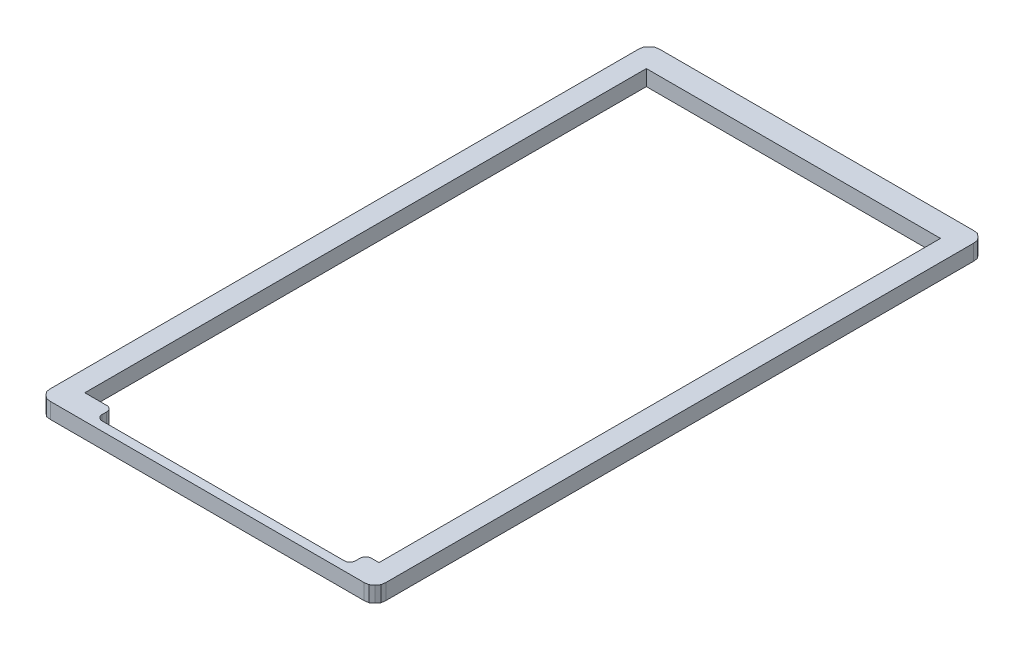
from build123d import *

# Parameters (mm, degrees)
AUFSATZ_LINEAR_AUSTRAGEN1_DEPTH = 1.4


with BuildPart() as part:
    # Skizze1 → Aufsatz-Linear austragen1 (new body)
    with BuildSketch(Plane(origin=(0, 0, 0), x_dir=(1, 0, 0), z_dir=(0, 1, 0))):
        Polygon((14.409630658, 25.21028647), (14.016111454, 25.259411872), (-14.016755293, 25.259390001), (-14.409855506, 25.210248977), (-14.705374814, 24.96453136), (-14.950840446, 24.669672719), (-15.000118678, 24.276547653), (-15.000218735, -28.257278341), (-14.95104056, -28.650375287), (-14.705137178, -28.945646353), (-14.410055621, -29.190951545), (-14.016949154, -29.240173804), (14.015942607, -29.240255039), (14.409480572, -29.191114015), (14.704562129, -28.945396398), (14.950465511, -28.650537758), (14.999712475, -28.257315834), (14.999781265, 24.276613266), (14.95060309, 24.669716461), (14.704274464, 24.964575102), align=None)
        with BuildLine():
            Line((11.462718603, -28.440255039), (-10.193671543, -28.440255039))
            ThreePointArc((-10.193671543, -28.440255039), (-10.547224933, -28.29380843), (-10.693671543, -27.940255039))
            Line((-10.693671543, -27.940255039), (-10.693671543, -27.530609999))
            ThreePointArc((-10.693671543, -27.530609999), (-10.840118152, -27.177056609), (-11.193671543, -27.030609999))
            Line((-11.193671543, -27.030609999), (-13.15, -27.030609999))
            Line((-13.15, -27.030609999), (-13.15, 23.169390001))
            Line((-13.15, 23.169390001), (13.15, 23.169390001))
            Line((13.15, 23.169390001), (13.15, -27.030609999))
            Line((13.15, -27.030609999), (12.462718603, -27.030609999))
            ThreePointArc((12.462718603, -27.030609999), (12.109165213, -27.177056609), (11.962718603, -27.530609999))
            Line((11.962718603, -27.530609999), (11.962718603, -27.940255039))
            ThreePointArc((11.962718603, -27.940255039), (11.816271994, -28.29380843), (11.462718603, -28.440255039))
        make_face(mode=Mode.SUBTRACT)
    extrude(amount=AUFSATZ_LINEAR_AUSTRAGEN1_DEPTH)


solid = part.part
